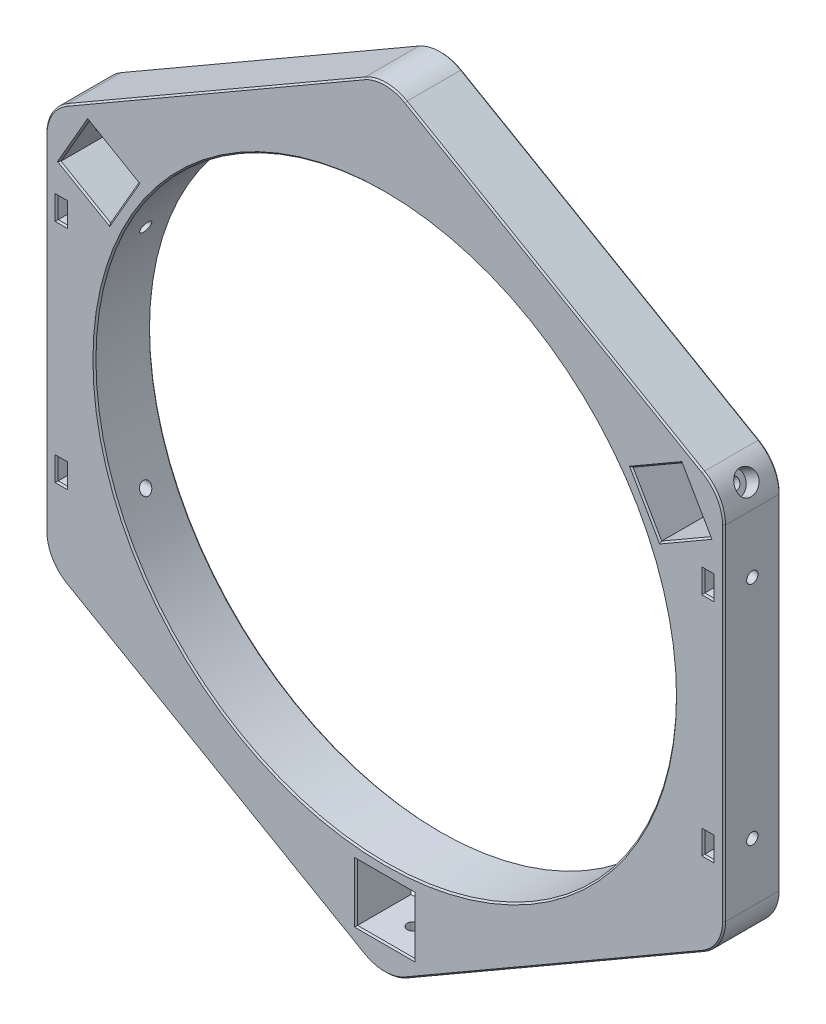
from build123d import *

# Parameters (mm, degrees)
SKETCH1_R           = 77
BOSS_EXTRUDE1_DEPTH = 15
SKETCH2_W           = 15.2
SKETCH2_H           = 15.2
CUT_EXTRUDE1_DEPTH  = 16
FILLET1_R           = 11.11
SKETCH9_R           = 1.5
CUT_EXTRUDE6_DEPTH  = 3
SKETCH10_R          = 3
CUT_EXTRUDE7_DEPTH  = 31.844449077
CIRPATTERN2_COUNT   = 3
SKETCH13_R          = 1.5
CUT_EXTRUDE10_DEPTH = 181.0000001
SKETCH14_W          = 2.5
SKETCH14_H          = 5.6
CUT_EXTRUDE11_DEPTH = 16.0000001
CHAMFER1_SIZE       = 0.4


with BuildPart() as part:
    # Sketch1 → Boss-Extrude1 (new body)
    with BuildSketch(Plane.XY):
        Polygon((0, 103.923048454), (90, 51.961524227), (90, -51.961524227), (0, -103.923048454), (-90, -51.961524227), (-90, 51.961524227), align=None)
        Circle(SKETCH1_R, mode=Mode.SUBTRACT)
    extrude(amount=BOSS_EXTRUDE1_DEPTH)

    # Sketch2 → Cut-Extrude1 (cut, through all)
    with BuildSketch(Plane.XY.offset(15)):
        with Locations((0, -87.6)):
            Rectangle(SKETCH2_W, SKETCH2_H)
        Polygon((-65.482032303, 46.581793069), (-73.082032303, 33.418206931), (-86.24561844, 41.018206931), (-78.64561844, 54.181793069), align=None)
        Polygon((73.082032303, 33.418206931), (65.482032303, 46.581793069), (78.64561844, 54.181793069), (86.24561844, 41.018206931), align=None)
    extrude(amount=-CUT_EXTRUDE1_DEPTH, mode=Mode.SUBTRACT)

    # Fillet1
    fillet1_edges = [part.edges().sort_by_distance(p)[0] for p in [
        (0, -103.923048454, 7.5),
        (-90, -51.961524227, 7.5),
        (-90, 51.961524227, 7.5),
        (0, 103.923048454, 7.5),
        (90, 51.961524227, 7.5),
        (90, -51.961524227, 7.5),
    ]]
    fillet(fillet1_edges, radius=FILLET1_R)

    # Sketch9 → Cut-Extrude6 (cut)
    with BuildSketch(Plane(origin=(-82.44561844, 47.6, 0), x_dir=(0, 0, -1), z_dir=(0.866025404, -0.5, 0))):
        with Locations((-7.5, 0)):
            Circle(SKETCH9_R)
    cut_extrude6 = extrude(amount=-CUT_EXTRUDE6_DEPTH, mode=Mode.SUBTRACT)

    # Sketch10 → Cut-Extrude7 (cut, through all)
    with BuildSketch(Plane(origin=(-85.043694652, 49.1, 0), x_dir=(0, 0, -1), z_dir=(0.866025404, -0.5, 0))):
        with Locations((-7.5, 0)):
            Circle(SKETCH10_R)
    cut_extrude7 = extrude(amount=-CUT_EXTRUDE7_DEPTH, mode=Mode.SUBTRACT)

    # CirPattern2: Cut-Extrude6, Cut-Extrude7 ×3 about axis
    cirpattern2_axis = Axis((0, 0, 0), (0, 0, 1))
    for i in range(1, CIRPATTERN2_COUNT):
        add(cut_extrude6.rotate(cirpattern2_axis, i * 360 / CIRPATTERN2_COUNT), mode=Mode.SUBTRACT)
        add(cut_extrude7.rotate(cirpattern2_axis, i * 360 / CIRPATTERN2_COUNT), mode=Mode.SUBTRACT)

    # Sketch13 → Cut-Extrude10 (cut, through all)
    with BuildSketch(Plane.ZY.offset(90)):
        with Locations((7.5, -30)):
            Circle(SKETCH13_R)
        with Locations((7.5, 30)):
            Circle(SKETCH13_R)
    extrude(amount=-CUT_EXTRUDE10_DEPTH, mode=Mode.SUBTRACT)

    # Sketch14 → Cut-Extrude11 (cut, through all)
    with BuildSketch(Plane.XY.offset(15)):
        with Locations((-85.75, 30)):
            Rectangle(SKETCH14_W, SKETCH14_H)
        with Locations((-85.75, -30)):
            Rectangle(SKETCH14_W, SKETCH14_H)
        with Locations((85.75, -30)):
            Rectangle(SKETCH14_W, SKETCH14_H)
        with Locations((85.75, 30)):
            Rectangle(SKETCH14_W, SKETCH14_H)
    extrude(amount=-CUT_EXTRUDE11_DEPTH, mode=Mode.SUBTRACT)

    # Chamfer1
    chamfer1_edges = [part.edges().sort_by_distance(p)[0] for p in [
        (-77, 0, 0),
        (-77, 0, 15),
        (87, 30, 0),
        (84.5, 30, 0),
        (85.75, 32.8, 0),
        (85.75, 27.2, 0),
        (85.75, 32.8, 15),
        (84.5, 30, 15),
        (85.75, 27.2, 15),
        (87, 30, 15),
        (87, -30, 0),
        (84.5, -30, 0),
        (85.75, -32.8, 0),
        (85.75, -27.2, 0),
        (87, -30, 15),
        (85.75, -27.2, 15),
        (84.5, -30, 15),
        (85.75, -32.8, 15),
        (-87, -30, 0),
        (-84.5, -30, 0),
        (-85.75, -32.8, 0),
        (-85.75, -27.2, 0),
        (-85.75, -32.8, 15),
        (-84.5, -30, 15),
        (-85.75, -27.2, 15),
        (-87, -30, 15),
        (-87, 30, 0),
        (-84.5, 30, 0),
        (-85.75, 32.8, 0),
        (-85.75, 27.2, 0),
        (-87, 30, 15),
        (-85.75, 27.2, 15),
        (-84.5, 30, 15),
        (-85.75, 32.8, 15),
        (7.6, -87.6, 0),
        (0, -95.2, 0),
        (-7.6, -87.6, 0),
        (0, -80, 0),
        (7.6, -87.6, 15),
        (0, -80, 15),
        (-7.6, -87.6, 15),
        (0, -95.2, 15),
        (-79.663825372, 37.218206931, 0),
        (-82.44561844, 47.6, 0),
        (-72.063825372, 50.381793069, 0),
        (-69.282032303, 40, 0),
        (-79.663825372, 37.218206931, 15),
        (-69.282032303, 40, 15),
        (-72.063825372, 50.381793069, 15),
        (-82.44561844, 47.6, 15),
        (72.063825372, 50.381793069, 0),
        (82.44561844, 47.6, 0),
        (79.663825372, 37.218206931, 0),
        (69.282032303, 40, 0),
        (72.063825372, 50.381793069, 15),
        (69.282032303, 40, 15),
        (79.663825372, 37.218206931, 15),
        (82.44561844, 47.6, 15),
        (-45, -77.942286341, 0),
        (-45, -77.942286341, 15),
        (45, -77.942286341, 0),
        (-90, 0, 0),
        (-45, 77.942286341, 0),
        (45, 77.942286341, 0),
        (90, 0, 0),
        (0, -102.204325473, 0),
        (88.511542236, -51.102162736, 0),
        (88.511542236, 51.102162736, 0),
        (0, 102.204325473, 0),
        (-88.511542236, 51.102162736, 0),
        (-88.511542236, -51.102162736, 0),
        (-90, 0, 15),
        (45, -77.942286341, 15),
        (90, 0, 15),
        (45, 77.942286341, 15),
        (-45, 77.942286341, 15),
        (0, -102.204325473, 15),
        (88.511542236, -51.102162736, 15),
        (88.511542236, 51.102162736, 15),
        (0, 102.204325473, 15),
        (-88.511542236, 51.102162736, 15),
        (-88.511542236, -51.102162736, 15),
    ]]
    chamfer(chamfer1_edges, length=CHAMFER1_SIZE)


solid = part.part
